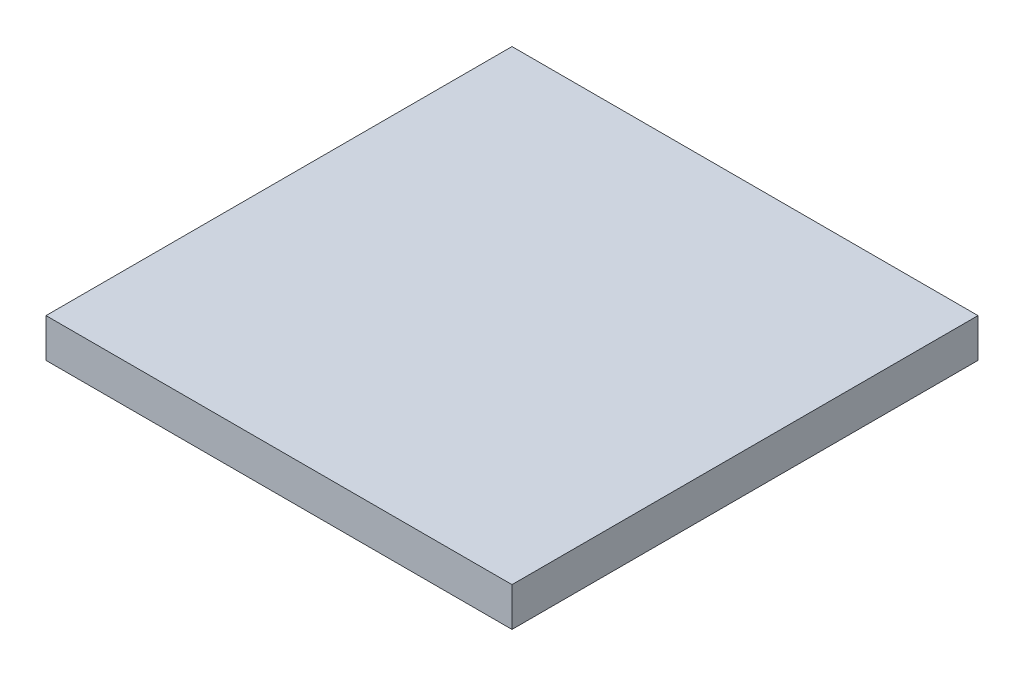
from build123d import *

# Parameters (mm, degrees)
SKETCH_1_W      = 12
SKETCH_1_H      = 12
EXTRUDE_1_DEPTH = 1


with BuildPart() as part:
    # Эскиз1 → Бобышка-Вытянуть1 (new body)
    with BuildSketch(Plane(origin=(0, 0, 0), x_dir=(1, 0, 0), z_dir=(0, 1, 0))):
        with Locations((6, 6)):
            Rectangle(SKETCH_1_W, SKETCH_1_H)
    extrude(amount=EXTRUDE_1_DEPTH)


solid = part.part
